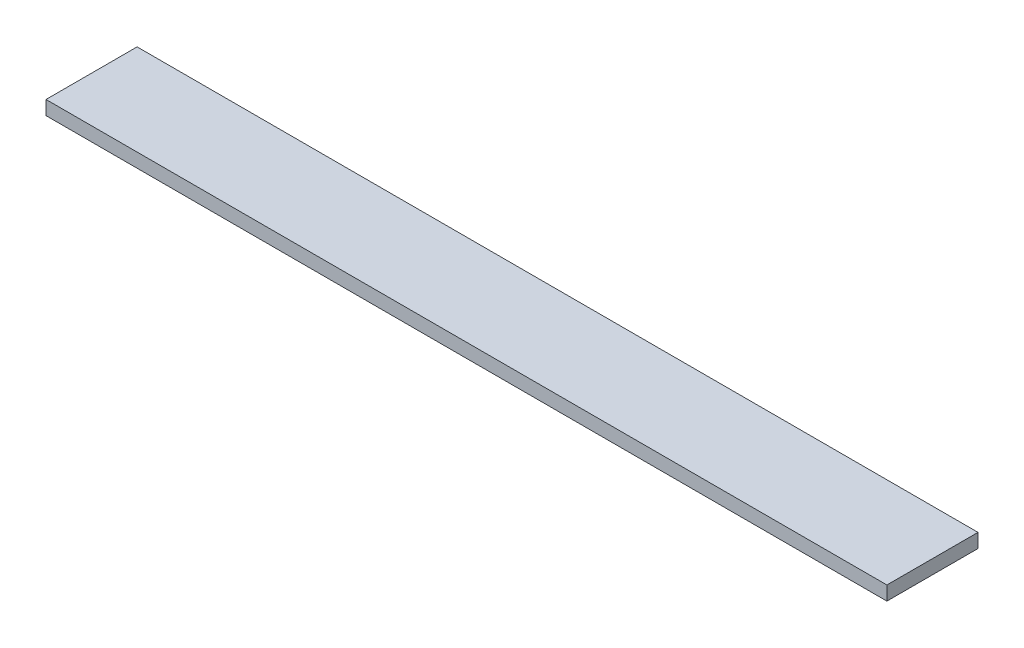
from build123d import *

# Parameters (mm, degrees)
SKETCH2_W           = 762
SKETCH2_H           = 82.55
BOSS_EXTRUDE1_DEPTH = 12.7


with BuildPart() as part:
    # Sketch2 → Boss-Extrude1 (new body)
    with BuildSketch(Plane(origin=(0, 0, 0), x_dir=(1, 0, 0), z_dir=(0, 1, 0))):
        with Locations((287.778461152, 8.180769215)):
            Rectangle(SKETCH2_W, SKETCH2_H)
    extrude(amount=BOSS_EXTRUDE1_DEPTH)


solid = part.part
